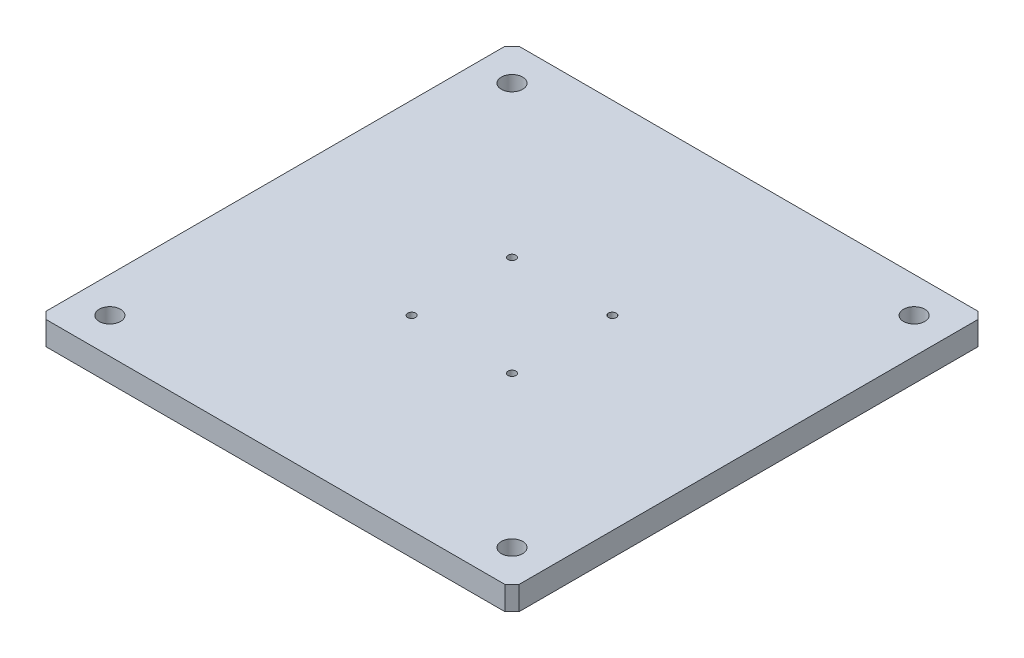
from build123d import *

# Parameters (mm, degrees)
SKETCH1_W             = 200
SKETCH1_H             = 200
BOSS_EXTRUDE1_DEPTH   = 10
M8_CLEARANCE_HOLE1_D  = 9
M4X0_7_TAPPED_HOLE1_D = 3.3
CHAMFER1_SIZE         = 3


with BuildPart() as part:
    # Sketch1 → Boss-Extrude1 (new body)
    with BuildSketch(Plane(origin=(0, 0, 0), x_dir=(1, 0, 0), z_dir=(0, 1, 0))):
        with Locations((100, 0)):
            Rectangle(SKETCH1_W, SKETCH1_H)
    extrude(amount=BOSS_EXTRUDE1_DEPTH)

    # M8 Clearance Hole1 (through all)
    with Locations(Plane(origin=(0, 10, 0), x_dir=(-1, 0, 0), z_dir=(0, 1, 0))):
        with Locations((-15, 85), (-15, -85), (-185, -85), (-185, 85)):
            Hole(M8_CLEARANCE_HOLE1_D / 2)

    # M4x0.7 Tapped Hole1 (through all)
    with Locations(Plane(origin=(0, 10, 0), x_dir=(-1, 0, 0), z_dir=(0, 1, 0))):
        with Locations((-78.786796564, 21.213203436), (-121.213203436, 21.213203436), (-121.213203436, -21.213203436), (-78.786796564, -21.213203436)):
            Hole(M4X0_7_TAPPED_HOLE1_D / 2)

    # Chamfer1
    chamfer1_edges = [part.edges().sort_by_distance(p)[0] for p in [
        (0, 5, -100),
        (200, 5, -100),
        (200, 5, 100),
        (0, 5, 100),
    ]]
    chamfer(chamfer1_edges, length=CHAMFER1_SIZE)


solid = part.part
